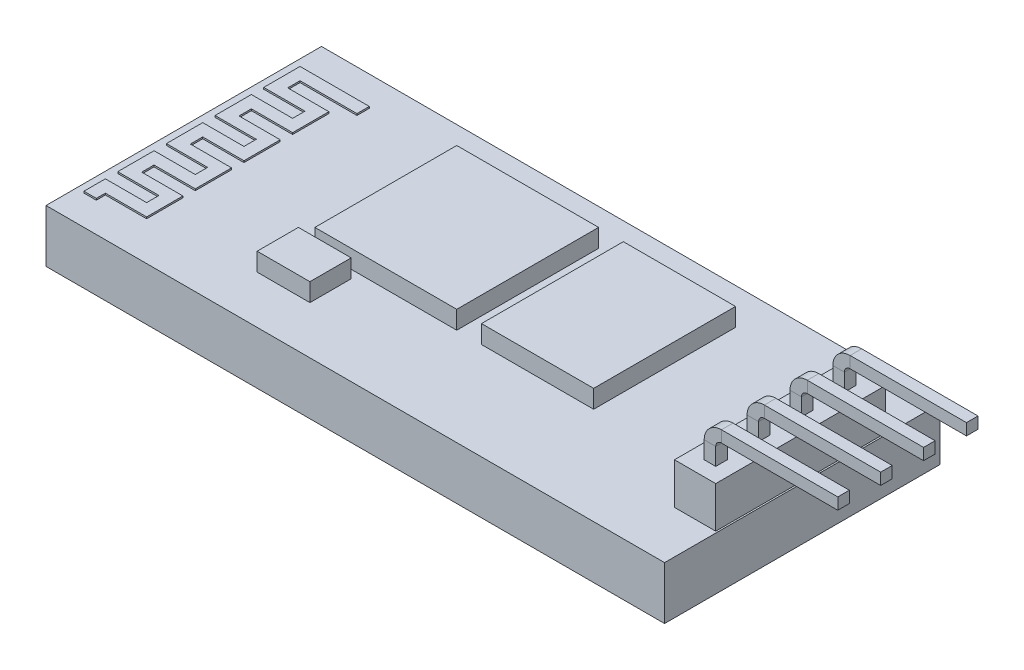
from build123d import *

# Parameters (mm, degrees)
SKETCH1_W           = 37.5
SKETCH1_H           = 16.7
BOSS_EXTRUDE1_DEPTH = 3.2
SKETCH2_W           = 8.6
SKETCH2_H           = 8.6
SKETCH2_W_2         = 6.8
SKETCH2_W_3         = 3.2
SKETCH2_H_2         = 2.5
BOSS_EXTRUDE2_DEPTH = 1.1
BOSS_EXTRUDE3_DEPTH = 0.1
SKETCH4_W           = 2.5
SKETCH4_H           = 10.3
BOSS_EXTRUDE4_DEPTH = 2.5
SKETCH5_W           = 2.5
SKETCH5_H           = 0.1
CUT_EXTRUDE1_DEPTH  = 0.2
SKETCH6_W           = 0.7
SKETCH6_H           = 0.7


with BuildPart() as part:
    # Sketch1 → Boss-Extrude1 (new body)
    with BuildSketch(Plane(origin=(0, 0, 0), x_dir=(1, 0, 0), z_dir=(0, 1, 0))):
        Rectangle(SKETCH1_W, SKETCH1_H)
    extrude(amount=BOSS_EXTRUDE1_DEPTH)

    # Sketch2 → Boss-Extrude2 (add)
    with BuildSketch(Plane(origin=(0, 3.2, 0), x_dir=(1, 0, 0), z_dir=(0, 1, 0))):
        with Locations((-4.05, 1.85)):
            Rectangle(SKETCH2_W, SKETCH2_H)
        with Locations((5.15, 1.85)):
            Rectangle(SKETCH2_W_2, SKETCH2_H)
        with Locations((-7.25, -4.2)):
            Rectangle(SKETCH2_W_3, SKETCH2_H_2)
    extrude(amount=BOSS_EXTRUDE2_DEPTH)

    # Sketch3 → Boss-Extrude3 (add)
    with BuildSketch(Plane(origin=(0, 3.2, 0), x_dir=(1, 0, 0), z_dir=(0, 1, 0))):
        Polygon((-14.05, 6.55), (-18.25, 6.55), (-18.25, 4.35), (-15.75, 4.35), (-15.75, 3.6), (-18.25, 3.6), (-18.25, 1.4), (-15.75, 1.4), (-15.75, 0.65), (-18.25, 0.65), (-18.25, -1.55), (-15.75, -1.55), (-15.75, -2.3), (-18.25, -2.3), (-18.25, -4.5), (-15.75, -4.5), (-15.75, -5.25), (-18.25, -5.25), (-18.25, -6.55), (-17.5, -6.55), (-17.5, -6), (-15, -6), (-15, -3.8), (-17.5, -3.8), (-17.5, -3.05), (-15, -3.05), (-15, -0.85), (-17.5, -0.85), (-17.5, -0.1), (-15, -0.1), (-15, 2.1), (-17.5, 2.1), (-17.5, 2.85), (-15, 2.85), (-15, 5.05), (-17.5, 5.05), (-17.5, 5.8), (-14.05, 5.8), align=None)
    extrude(amount=BOSS_EXTRUDE3_DEPTH)

    # Sketch4 → Boss-Extrude4 (add)
    with BuildSketch(Plane(origin=(0, 3.2, 0), x_dir=(1, 0, 0), z_dir=(0, 1, 0))):
        with Locations((17.4, 0)):
            Rectangle(SKETCH4_W, SKETCH4_H)
    extrude(amount=BOSS_EXTRUDE4_DEPTH)

    # Sketch5 → Cut-Extrude1 (cut)
    with BuildSketch(Plane(origin=(0, 5.7, 0), x_dir=(1, 0, 0), z_dir=(0, 1, 0))):
        with Locations((17.4, 2.6)):
            Rectangle(SKETCH5_W, SKETCH5_H)
        with Locations((17.4, -2.6)):
            Rectangle(SKETCH5_W, SKETCH5_H)
        with Locations((17.4, 0)):
            Rectangle(SKETCH5_W, SKETCH5_H)
    extrude(amount=-CUT_EXTRUDE1_DEPTH, mode=Mode.SUBTRACT)

    # Sweep1: sweep along a path in Sketch7
    with BuildLine(Plane.XY) as sweep1_path:
        Line((17.4, 5.7), (17.4, 6.75))
        ThreePointArc((17.4, 6.75), (17.605025253, 7.244974747), (18.1, 7.45))
        Line((18.1, 7.45), (25.15, 7.45))
    # Sketch6 → Sweep1 (sweep)
    with BuildSketch(Plane(origin=(0, 5.7, 0), x_dir=(1, 0, 0), z_dir=(0, 1, 0))):
        with Locations((17.4, 3.9)):
            Rectangle(SKETCH6_W, SKETCH6_H)
        with Locations((17.4, 1.3)):
            Rectangle(SKETCH6_W, SKETCH6_H)
        with Locations((17.4, -1.3)):
            Rectangle(SKETCH6_W, SKETCH6_H)
        with Locations((17.4, -3.9)):
            Rectangle(SKETCH6_W, SKETCH6_H)
    sweep(path=sweep1_path.line)


solid = part.part
